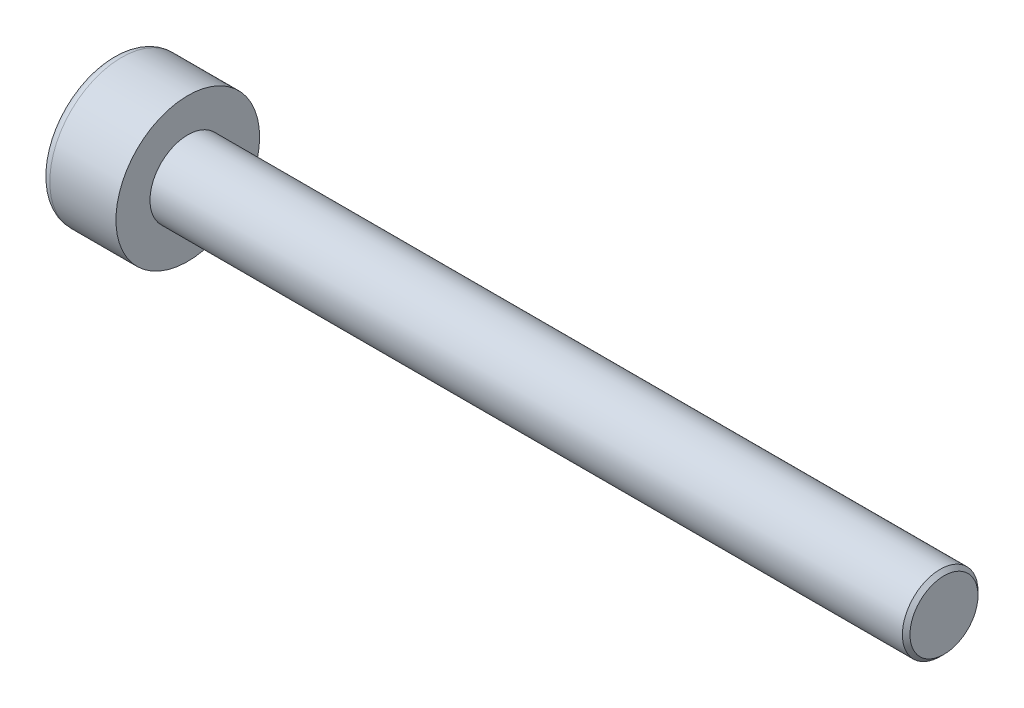
from build123d import *

# Parameters (mm, degrees)
SKETCH1_R           = 1.9
BASEHEAD_DEPTH      = 2
SKETCH2_R           = 1
BASEBODY_DEPTH      = 20
HEXAGONSOCKET_DEPTH = 1
TOPFILLET_R         = 0.25
CHAMFER1_SIZE       = 0.1


with BuildPart() as part:
    # Sketch1 → BaseHead (new body)
    with BuildSketch(Plane(origin=(0, 0, 0), x_dir=(0, 0, -1), z_dir=(1, 0, 0))):
        Circle(SKETCH1_R)
    extrude(amount=BASEHEAD_DEPTH)

    # Sketch2 → BaseBody (add)
    with BuildSketch(Plane(origin=(2, 0, 0), x_dir=(0, 0, -1), z_dir=(1, 0, 0))):
        Circle(SKETCH2_R)
    extrude(amount=BASEBODY_DEPTH)

    # Sketch3 → HexagonSocket (cut)
    with BuildSketch(Plane(origin=(0, 0, 0), x_dir=(0, 0, -1), z_dir=(1, 0, 0))):
        Polygon((0.866025404, 0), (0.433012702, 0.75), (-0.433012702, 0.75), (-0.866025404, 0), (-0.433012702, -0.75), (0.433012702, -0.75), align=None)
    extrude(amount=HEXAGONSOCKET_DEPTH, mode=Mode.SUBTRACT)

    # Sketch4 → Cut-Revolve1 (revolve, cut)
    with BuildSketch(Plane(origin=(-4.19613823, 0.75, 0), x_dir=(-1, 0, 0), z_dir=(0, 0, 1))):
        Polygon((-5.19613823, 1.5), (-5.629150931, 0.75), (-5.19613823, 0.75), align=None)
    revolve(axis=Axis((0.838992387, 0, 0), (-1, 0, 0)), mode=Mode.SUBTRACT)

    # TopFillet
    topfillet_edges = [part.edges().sort_by_distance(p)[0] for p in [
        (0, 0, 1.9),
    ]]
    fillet(topfillet_edges, radius=TOPFILLET_R)

    # Chamfer1
    chamfer1_edges = [part.edges().sort_by_distance(p)[0] for p in [
        (22, 0, 1),
    ]]
    chamfer(chamfer1_edges, length=CHAMFER1_SIZE)


solid = part.part
